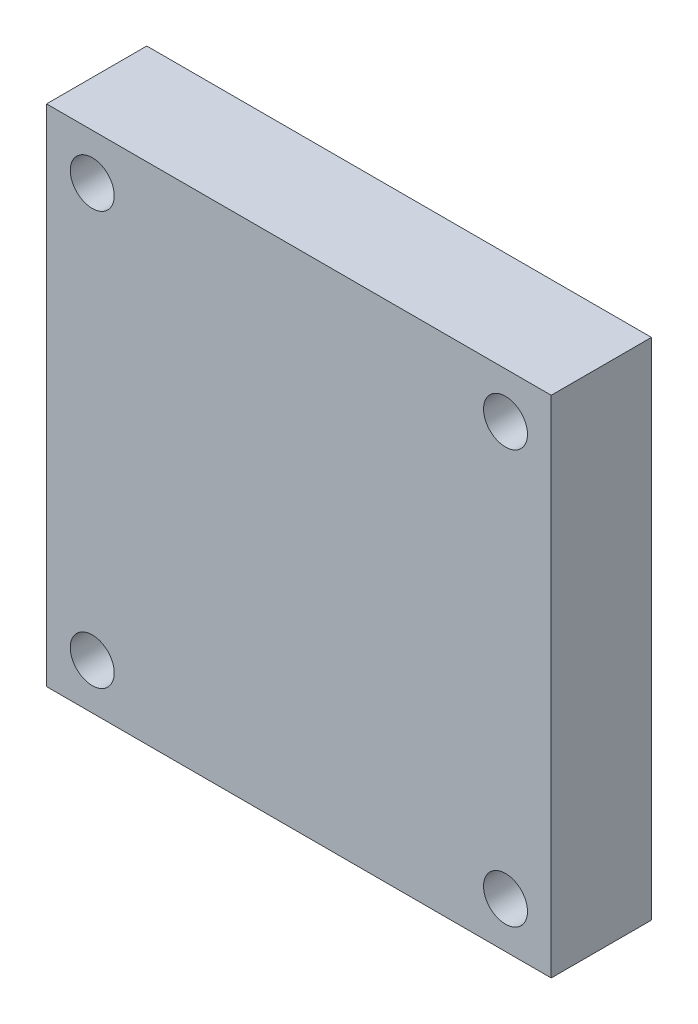
from build123d import *

# Parameters (mm, degrees)
AUFSATZ_LINEAR_AUSTRAGEN1_DEPTH = 11.4
F_5_0_5_DURCHMESSER_BOHRUNG1_D  = 5


with BuildPart() as part:
    # Skizze1 → Aufsatz-Linear austragen1 (new body)
    with BuildSketch(Plane.XY):
        Polygon((28.7, -28.7), (28.7, 0), (28.7, 28.7), (-28.7, 28.7), (-28.7, -28.7), align=None)
    extrude(amount=AUFSATZ_LINEAR_AUSTRAGEN1_DEPTH)

    # Ø5.0 (5) Durchmesser Bohrung1 (through all)
    with Locations(Plane.XY.offset(11.4)):
        with Locations((-23.5, 23.5), (23.5, 23.5), (23.5, -23.5), (-23.5, -23.5)):
            Hole(F_5_0_5_DURCHMESSER_BOHRUNG1_D / 2)


solid = part.part
